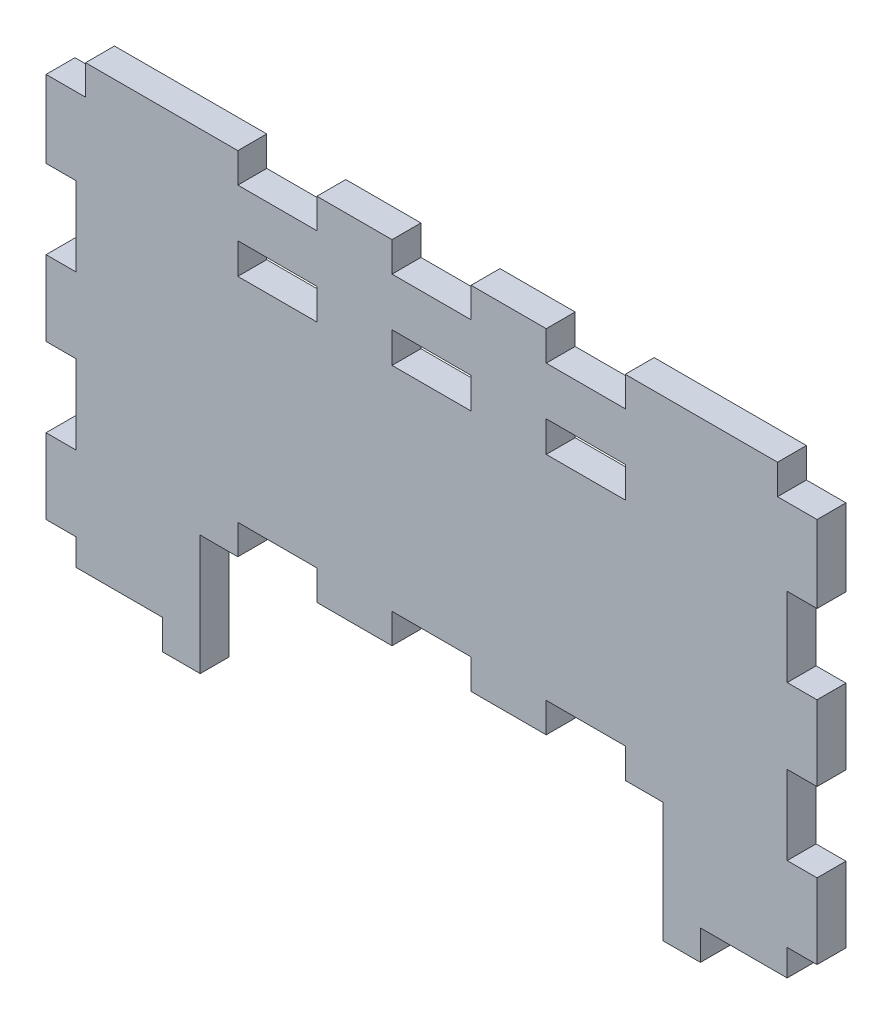
from build123d import *

# Parameters (mm, degrees)
BOSS_EXTRUDE1_DEPTH = 3
SKETCH3_W           = 4.2
SKETCH3_H           = 3.2
SKETCH3_W_2         = 3.2
SKETCH3_H_2         = 8.2
SKETCH3_W_3         = 8.2
CUT_EXTRUDE1_DEPTH  = 4


with BuildPart() as part:
    # Sketch1 → Boss-Extrude1 (new body)
    with BuildSketch(Plane.XY):
        Polygon((0, 52.125), (80, 52.125), (80, 3.175), (64, 3.175), (64, 15.625), (16, 15.625), (16, 3.175), (0, 3.175), align=None)
    extrude(amount=-BOSS_EXTRUDE1_DEPTH)

    # Sketch3 → Cut-Extrude1 (cut, through all)
    with BuildSketch(Plane.XY):
        with Locations((2, 50.625)):
            Rectangle(SKETCH3_W, SKETCH3_H)
        with Locations((1.5, 20.925)):
            Rectangle(SKETCH3_W_2, SKETCH3_H_2)
        with Locations((24, 17.125)):
            Rectangle(SKETCH3_W_3, SKETCH3_H)
        with Locations((40, 17.125)):
            Rectangle(SKETCH3_W_3, SKETCH3_H)
        with Locations((1.5, 36.925)):
            Rectangle(SKETCH3_W_2, SKETCH3_H_2)
        with Locations((40, 50.625)):
            Rectangle(SKETCH3_W_3, SKETCH3_H)
        with Locations((40, 42.425)):
            Rectangle(SKETCH3_W_3, SKETCH3_H)
        with Locations((24, 42.425)):
            Rectangle(SKETCH3_W_3, SKETCH3_H)
        with Locations((24, 50.625)):
            Rectangle(SKETCH3_W_3, SKETCH3_H)
        with Locations((56, 42.425)):
            Rectangle(SKETCH3_W_3, SKETCH3_H)
        with Locations((56, 17.125)):
            Rectangle(SKETCH3_W_3, SKETCH3_H)
        with Locations((78.5, 36.925)):
            Rectangle(SKETCH3_W_2, SKETCH3_H_2)
        with Locations((78, 50.625)):
            Rectangle(SKETCH3_W, SKETCH3_H)
        with Locations((78.5, 20.925)):
            Rectangle(SKETCH3_W_2, SKETCH3_H_2)
        with Locations((56, 50.625)):
            Rectangle(SKETCH3_W_3, SKETCH3_H)
        Polygon((76.9, 9.025), (76.9, 6.275), (67.9, 6.275), (67.9, 3.075), (80.1, 3.075), (80.1, 9.025), align=None)
        Polygon((3.1, 6.275), (3.1, 9.025), (-0.1, 9.025), (-0.1, 3.075), (12.1, 3.075), (12.1, 6.275), align=None)
    extrude(amount=-CUT_EXTRUDE1_DEPTH, mode=Mode.SUBTRACT)


solid = part.part
